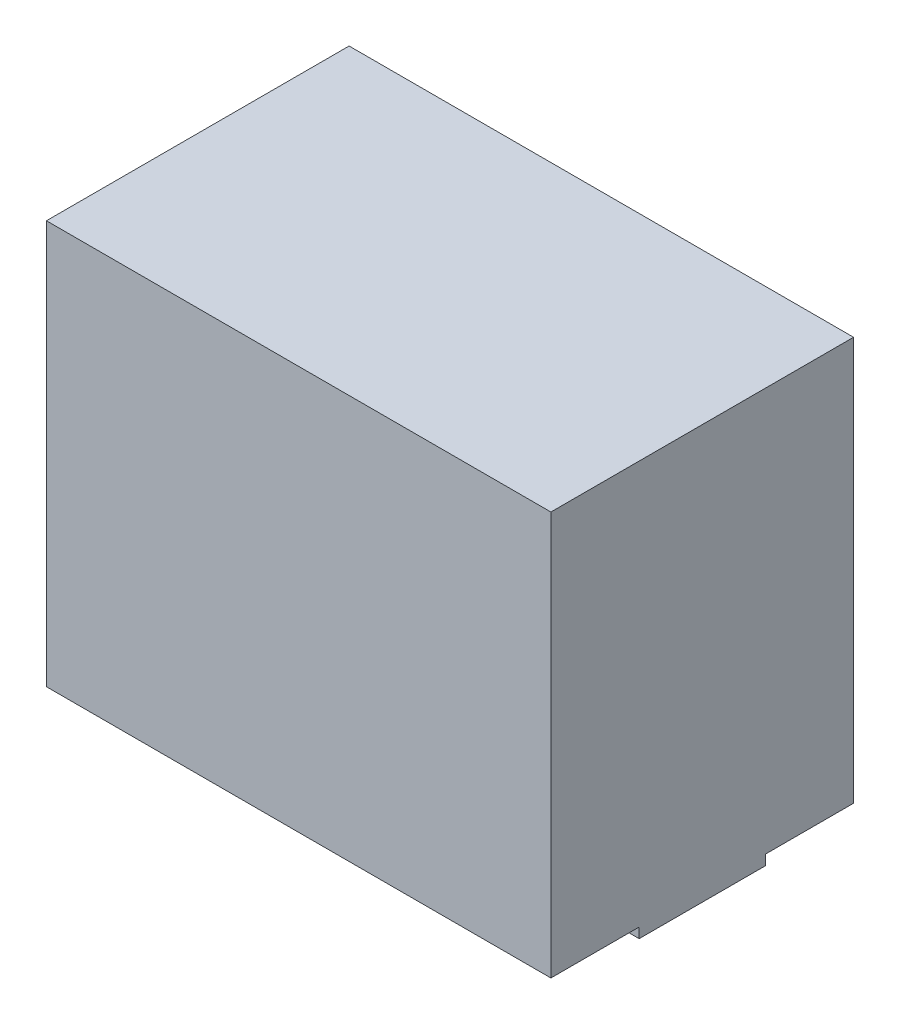
from build123d import *

# Parameters (mm, degrees)
SKETCH1_W           = 1
SKETCH1_H           = 0.6
BOSS_EXTRUDE1_DEPTH = 0.8
SKETCH3_W           = 0.2
SKETCH3_H           = 0.25
BOSS_EXTRUDE2_DEPTH = 0.02


with BuildPart() as part:
    # Sketch1 → Boss-Extrude1 (new body)
    with BuildSketch(Plane(origin=(0, 0, 0), x_dir=(1, 0, 0), z_dir=(0, 1, 0))):
        with Locations((0.5, 0.3)):
            Rectangle(SKETCH1_W, SKETCH1_H)
    extrude(amount=BOSS_EXTRUDE1_DEPTH)

    # Sketch3 → Boss-Extrude2 (add)
    with BuildSketch(Plane.XZ):
        with Locations((0.1, -0.3)):
            Rectangle(SKETCH3_W, SKETCH3_H)
        with Locations((0.9, -0.3)):
            Rectangle(SKETCH3_W, SKETCH3_H)
    extrude(amount=BOSS_EXTRUDE2_DEPTH)


solid = part.part
